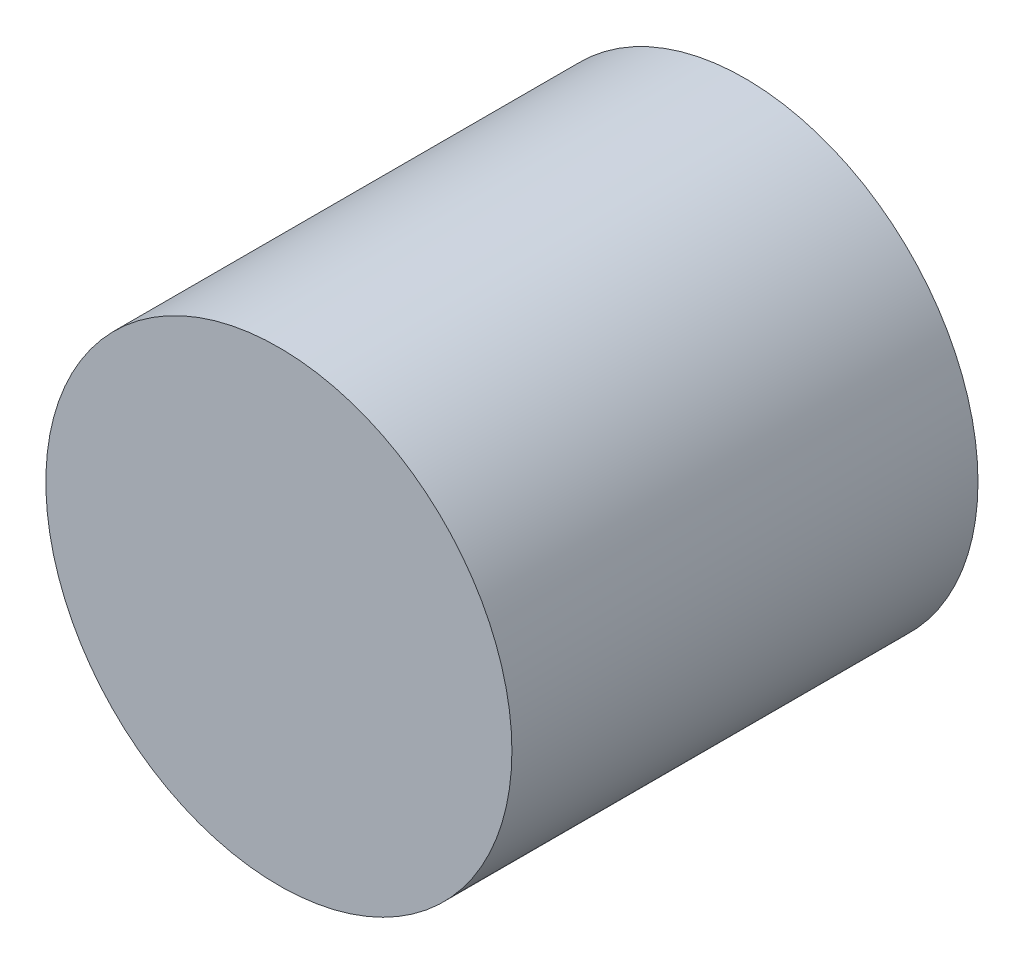
from build123d import *

# Parameters (mm, degrees)
SKETCH3_R           = 2
BOSS_EXTRUDE1_DEPTH = 4


with BuildPart() as part:
    # Sketch3 → Boss-Extrude1 (new body)
    with BuildSketch(Plane.XY):
        Circle(SKETCH3_R)
    extrude(amount=BOSS_EXTRUDE1_DEPTH)


solid = part.part
